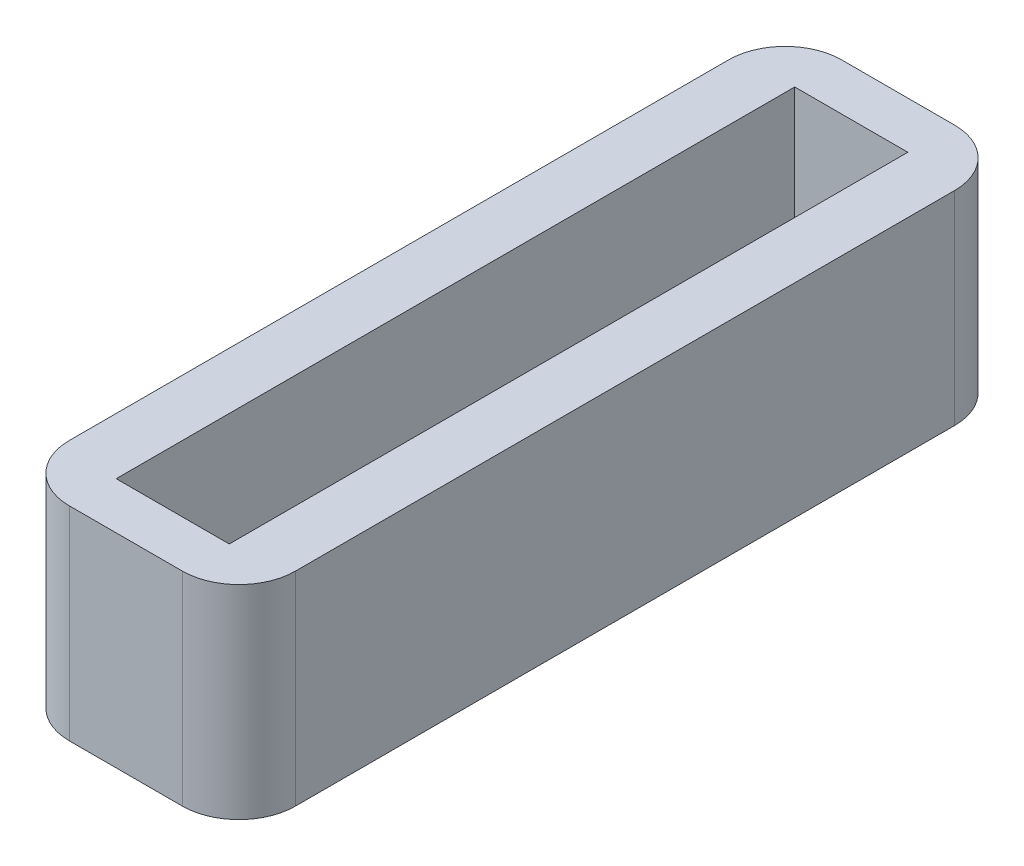
from build123d import *

# Parameters (mm, degrees)
SKETCH3_W           = 4
SKETCH3_H           = 13.659438398
SKETCH3_W_2         = 2
SKETCH3_H_2         = 12
BOSS_EXTRUDE3_DEPTH = 3.6
FILLET1_R           = 1


with BuildPart() as part:
    # Sketch3 → Boss-Extrude3 (new body)
    with BuildSketch(Plane(origin=(0, 0, 0), x_dir=(1, 0, 0), z_dir=(0, 1, 0))):
        Rectangle(SKETCH3_W, SKETCH3_H)
        Rectangle(SKETCH3_W_2, SKETCH3_H_2, mode=Mode.SUBTRACT)
    extrude(amount=BOSS_EXTRUDE3_DEPTH)

    # Fillet1
    fillet1_edges = [part.edges().sort_by_distance(p)[0] for p in [
        (2, 1.8, 6.829719199),
        (-2, 1.8, 6.829719199),
        (-2, 1.8, -6.829719199),
        (2, 1.8, -6.829719199),
    ]]
    fillet(fillet1_edges, radius=FILLET1_R)


solid = part.part
